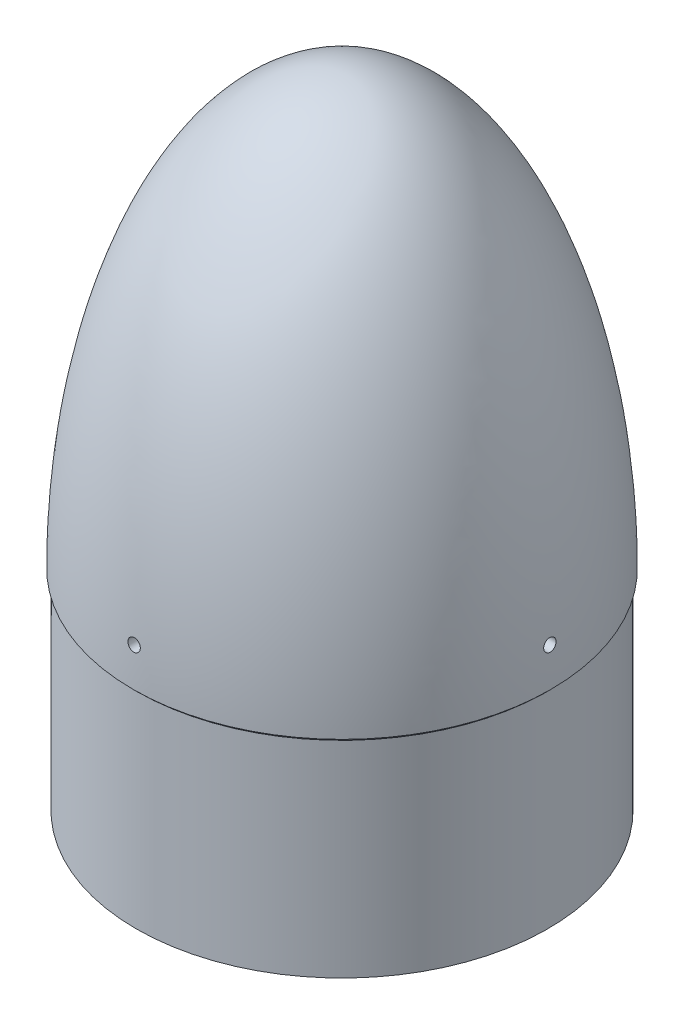
from build123d import *

# Parameters (mm, degrees)
BOSS_EXTRUDE1_START = -11.43
BOSS_EXTRUDE1_DEPTH = 22.86
SKETCH3_R           = 2.38125
CUT_EXTRUDE1_DEPTH  = 239.515332253
CIRPATTERN1_COUNT   = 4
BOSS_EXTRUDE2_DEPTH = 6.35


with BuildPart() as part:
    # Sketch1 → Revolve1 (revolve)
    with BuildSketch(Plane.XY, mode=Mode.PRIVATE) as revolve1_sk:
        with BuildLine():
            Line((0, 165.1), (0, 162.1028))
            add(Edge.make_bspline(
                [(79.315278355, 1.342862767), (78.663627327, 162.1028), (0, 162.1028)],
                knots=[4.720673095, 4.720673095, 4.720673095, 6.283185307, 6.283185307, 6.283185307], degree=2, weights=[1, 0.710029584, 1]))
            Line((79.315278355, 1.342862767), (77.575, -0.397415588))
            Line((77.575, -0.397415588), (77.575, -80.518))
            Line((77.575, -80.518), (79.375, -80.518))
            Line((79.375, -80.518), (79.375, -1.143))
            Line((79.375, -1.143), (80.518, 0))
            add(Edge.make_bspline(
                [(80.518, 0), (80.518, 165.1), (0, 165.1)],
                knots=[1.570796327, 1.570796327, 1.570796327, 3.141592654, 3.141592654, 3.141592654], degree=2, weights=[1, 0.707106781, 1]))
        make_face()
    revolve(revolve1_sk.sketch.rotate(Axis((0, 165.1, 0), (0, -1, 0)), 90), axis=Axis((0, 165.1, 0), (0, -1, 0)))

    # Sketch6 → Boss-Extrude1 (add)
    with BuildSketch(Plane.XY.offset(BOSS_EXTRUDE1_START)):
        with BuildLine():
            Line((73.66, 21.470281301), (78.034242777, 29.046692038))
            add(Edge.make_bspline(
                [(79.062314745, 13.005354783), (78.744364926, 21.078512305), (78.034242777, 29.046692038)],
                knots=[4.792704356, 4.792704356, 4.792704356, 4.892548854, 4.892548854, 4.892548854], degree=2, weights=[1, 0.998754143, 1]))
            add(Edge.make_bspline(
                [(79.315278355, 1.342862767), (79.29160326, 7.183422549), (79.062314745, 13.005354783)],
                knots=[4.720673095, 4.720673095, 4.720673095, 4.792704356, 4.792704356, 4.792704356], degree=2, weights=[1, 0.999351507, 1]))
            Line((79.315278355, 1.342862767), (77.575, -0.397415588))
            Line((77.575, -0.397415588), (77.575, -18.537382644))
            Line((77.575, -18.537382644), (73.66, -11.756403732))
            Line((73.66, -11.756403732), (73.66, 17.13351746))
            Line((73.66, 17.13351746), (73.66, 21.470281301))
        make_face()
    boss_extrude1 = extrude(amount=BOSS_EXTRUDE1_DEPTH)

    # Sketch3 → Cut-Extrude1 (cut, through all)
    with BuildSketch(Plane.ZY.offset(-71.628)):
        with Locations(Location((0, 14.732, 0), (0, 0, 270))):
            Circle(SKETCH3_R)
    cut_extrude1 = extrude(amount=-CUT_EXTRUDE1_DEPTH, mode=Mode.SUBTRACT)

    # CirPattern1: Boss-Extrude1, Cut-Extrude1 ×4 about axis
    cirpattern1_axis = Axis((0, 0, 0), (0, 1, 0))
    add([boss_extrude1.rotate(cirpattern1_axis, i * 360 / CIRPATTERN1_COUNT) for i in range(1, CIRPATTERN1_COUNT)])
    add([cut_extrude1.rotate(cirpattern1_axis, i * 360 / CIRPATTERN1_COUNT) for i in range(1, CIRPATTERN1_COUNT)], mode=Mode.SUBTRACT)

    # Sketch7 → Boss-Extrude2 (add, symmetric)
    with BuildSketch(Plane(origin=(0, -74.168, 0), x_dir=(1, 0, 0), z_dir=(0, 0, 1))):
        with BuildLine():
            Line((73.66, 95.638281301), (78.034242777, 103.214692038))
            add(Edge.make_bspline(
                [(78.034242777, 103.214692038), (76.413302416, 121.403033529), (72.830065055, 138.378377261)],
                knots=[1.750956201, 1.750956201, 1.750956201, 1.978071652, 1.978071652, 1.978071652], degree=2, weights=[1, 0.993559247, 1]))
            Line((72.830065055, 138.378377261), (73.66, 95.638281301))
        make_face()
    extrude(amount=BOSS_EXTRUDE2_DEPTH, both=True)


solid = part.part
